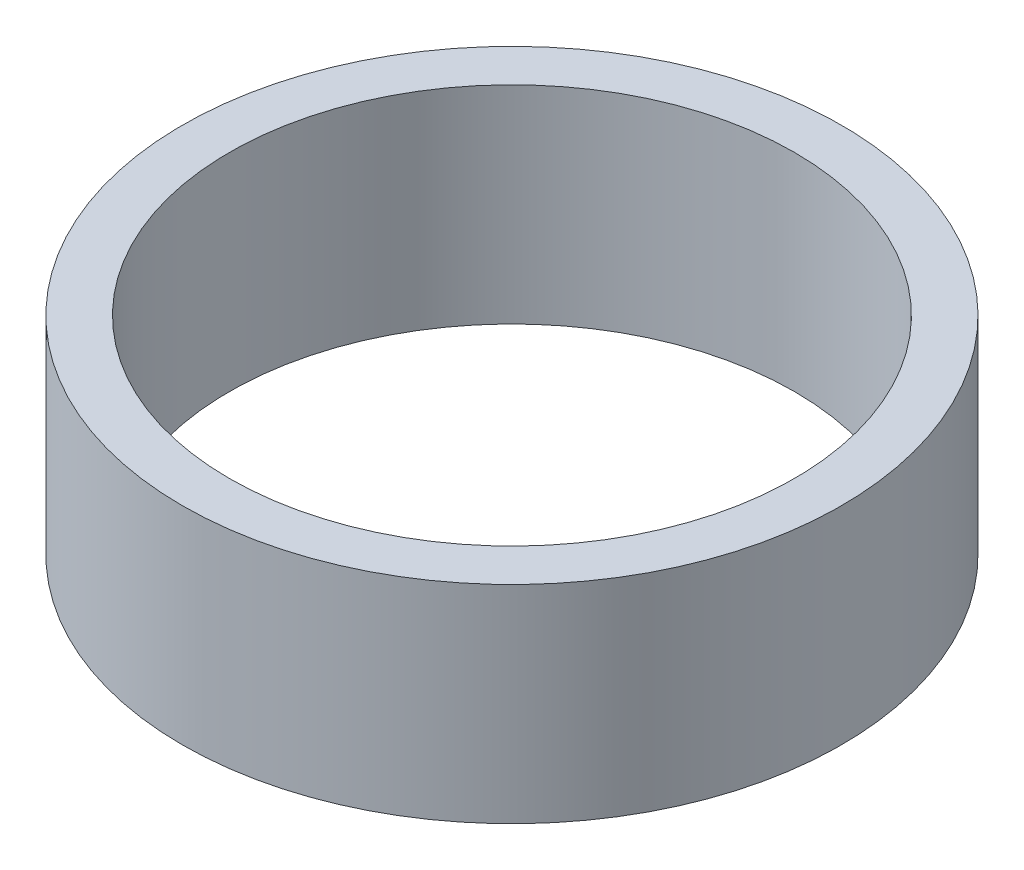
from build123d import *

# Parameters (mm, degrees)
SKETCH1_R           = 7
SKETCH1_R_2         = 6
BOSS_EXTRUDE1_DEPTH = 4.4


with BuildPart() as part:
    # Sketch1 → Boss-Extrude1 (new body)
    with BuildSketch(Plane(origin=(0, 0, 0), x_dir=(1, 0, 0), z_dir=(0, 1, 0))):
        Circle(SKETCH1_R)
        Circle(SKETCH1_R_2, mode=Mode.SUBTRACT)
    extrude(amount=BOSS_EXTRUDE1_DEPTH)


solid = part.part
